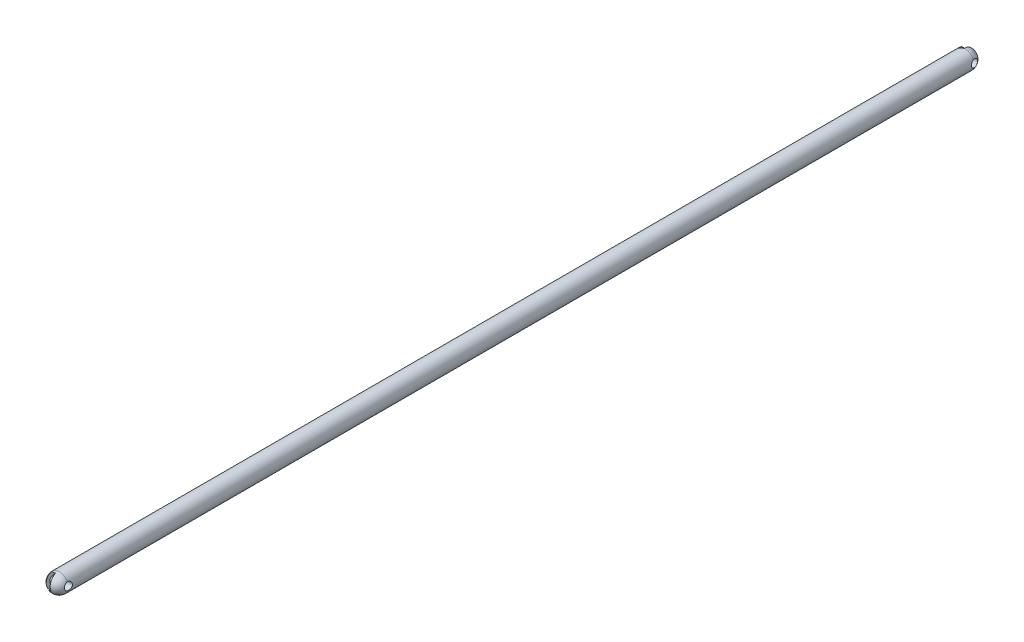
from build123d import *

# Parameters (mm, degrees)
SKETCH1_R               = 5
DOME1_FACE_RADIUS       = 5
DOME1_HEIGHT            = 5
DOME2_FACE_RADIUS       = 5
DOME2_HEIGHT            = 5
CUT_EXTRUDE2_DEPTH      = 5.404285297
CUT_EXTRUDE2_DEPTH_BACK = 289.404285297
SKETCH6_R               = 2
CUT_EXTRUDE3_DEPTH      = 68.142339226
CUT_EXTRUDE3_DEPTH_BACK = 6.72259346
CUT_EXTRUDE5_DEPTH      = 5.047319689
CUT_EXTRUDE5_DEPTH_BACK = 410.929194171
SKETCH8_R               = 2
CUT_EXTRUDE6_DEPTH      = 6.613212564
CUT_EXTRUDE6_DEPTH_BACK = 25.970742243


with BuildPart() as part:
    # Sweep1: sweep along a path in Sketch3
    with BuildLine(Plane(origin=(0, 0, 0), x_dir=(0, 0, -1), z_dir=(1, 0, 0))) as sweep1_path:
        Line((0, 0), (487.405602585, 0))
    # Sketch1 → Sweep1 (sweep)
    with BuildSketch(Plane.XY):
        Circle(SKETCH1_R)
    sweep(path=sweep1_path.line)

    # Dome1: a dome of height H over a round flat face of radius A is a cap of a sphere of radius (A * A + H * H) / (2 * H)
    dome1_r = (DOME1_FACE_RADIUS * DOME1_FACE_RADIUS + DOME1_HEIGHT * DOME1_HEIGHT) / (2 * DOME1_HEIGHT)
    dome1_base = Plane((0, 0, 0), z_dir=(0, 0, 1))
    with Locations(dome1_base.offset(DOME1_HEIGHT - dome1_r)):
        dome1_ball = Sphere(dome1_r, mode=Mode.PRIVATE)
    add(split(dome1_ball, bisect_by=dome1_base, keep=Keep.TOP, mode=Mode.PRIVATE))

    # Dome2: a dome of height H over a round flat face of radius A is a cap of a sphere of radius (A * A + H * H) / (2 * H)
    dome2_r = (DOME2_FACE_RADIUS * DOME2_FACE_RADIUS + DOME2_HEIGHT * DOME2_HEIGHT) / (2 * DOME2_HEIGHT)
    dome2_base = Plane((0, 0, -487.405602585), z_dir=(0, 0, -1))
    with Locations(dome2_base.offset(DOME2_HEIGHT - dome2_r)):
        dome2_ball = Sphere(dome2_r, mode=Mode.PRIVATE)
    add(split(dome2_ball, bisect_by=dome2_base, keep=Keep.TOP, mode=Mode.PRIVATE))

    # Sketch5 → Cut-Extrude2 (cut, two sides)
    with BuildSketch(Plane(origin=(-26.571757691, 229.275990101, -160.273085877), x_dir=(0.995516802, 0.078714536, -0.052443479), z_dir=(-0.094561415, 0.81592879, -0.570366854))) as cut_extrude2_sk:
        Polygon((22.843463066, 396.275337774), (22.1233695, 404.242954928), (25.111191904, 404.512986939), (25.831285469, 396.545369785), align=None)
    extrude(amount=CUT_EXTRUDE2_DEPTH, mode=Mode.SUBTRACT)
    extrude(cut_extrude2_sk.sketch, amount=-CUT_EXTRUDE2_DEPTH_BACK, mode=Mode.SUBTRACT)

    # Sketch6 → Cut-Extrude3 (cut, two sides)
    with BuildSketch(Plane(origin=(60.907834636, 1.64848777, -7.739724677), x_dir=(0.126296417, -0.009108801, 0.991950727), z_dir=(-0.991665366, -0.026839704, 0.126013623))) as cut_extrude3_sk:
        with Locations((-483.482341842, -6.054864831)):
            Circle(SKETCH6_R)
    extrude(amount=CUT_EXTRUDE3_DEPTH, mode=Mode.SUBTRACT)
    extrude(cut_extrude3_sk.sketch, amount=-CUT_EXTRUDE3_DEPTH_BACK, mode=Mode.SUBTRACT)

    # Sketch7 → Cut-Extrude5 (cut, two sides)
    with BuildSketch(Plane(origin=(-0.052668832, 1.714434817, 2.461288129), x_dir=(0.999845409, 0.010828351, 0.013852985), z_dir=(-0.017556277, 0.571478272, 0.820429376))) as cut_extrude5_sk:
        Polygon((-2.594541679, -4.452930477), (0.392284328, -4.172091725), (-0.280838752, 2.986826007), (-3.267664759, 2.705987255), align=None)
    extrude(amount=CUT_EXTRUDE5_DEPTH, mode=Mode.SUBTRACT)
    extrude(cut_extrude5_sk.sketch, amount=-CUT_EXTRUDE5_DEPTH_BACK, mode=Mode.SUBTRACT)

    # Sketch8 → Cut-Extrude6 (cut, two sides)
    with BuildSketch(Plane(origin=(0, 0, 0), x_dir=(0.039771244, 0.001105127, 0.9992082), z_dir=(-0.995364213, -0.087594482, 0.039715122))) as cut_extrude6_sk:
        Circle(SKETCH8_R)
    extrude(amount=CUT_EXTRUDE6_DEPTH, mode=Mode.SUBTRACT)
    extrude(cut_extrude6_sk.sketch, amount=-CUT_EXTRUDE6_DEPTH_BACK, mode=Mode.SUBTRACT)


solid = part.part
